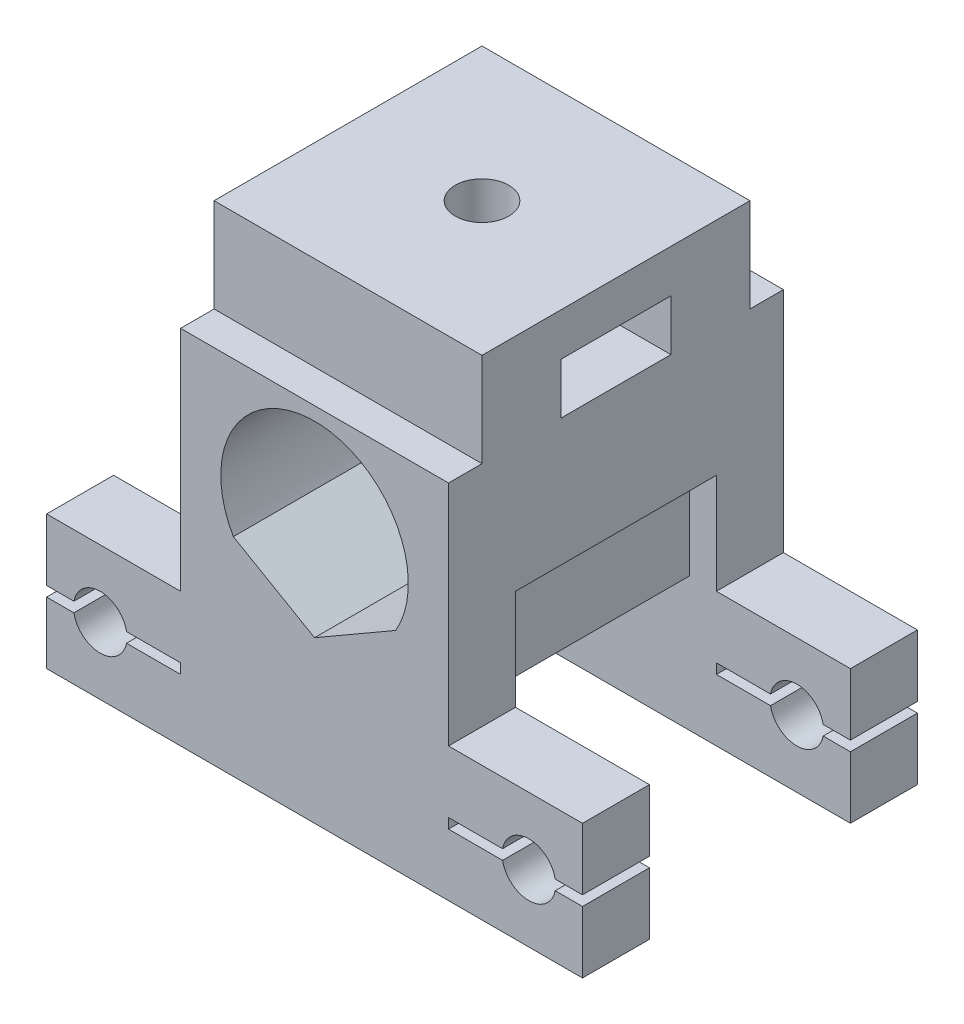
from build123d import *

# Parameters (mm, degrees)
SKETCH1_W               = 20
SKETCH1_H               = 25
BOSS_EXTRUDE1_DEPTH     = 17
CUT_EXTRUDE1_DEPTH      = 32.843366656
BOSS_EXTRUDE2_DEPTH     = 5
SKETCH4_R               = 2
CUT_EXTRUDE2_DEPTH      = 37.249137921
SKETCH6_W               = 20
SKETCH6_H               = 20
BOSS_EXTRUDE3_DEPTH     = 7
SKETCH8_W               = 8.2
SKETCH8_H               = 3.8
CUT_EXTRUDE3_DEPTH      = 41.401113846
CUT_EXTRUDE4_REACH      = 43.379
CUT_EXTRUDE4_END_RADIUS = 7
SKETCH7_R               = 2
SKETCH9_W               = 15
SKETCH9_H               = 7.5
CUT_EXTRUDE5_DEPTH      = 2
SKETCH10_W              = 10
SKETCH10_H              = 0.75
CUT_EXTRUDE6_DEPTH      = 41.01249811
CUT_EXTRUDE7_START      = 20
SKETCH9_2_W             = 15
SKETCH9_2_H             = 7.5
CUT_EXTRUDE7_DEPTH      = 2.5


with BuildPart() as part:
    # Sketch1 → Boss-Extrude1 (new body)
    with BuildSketch(Plane(origin=(0, 0, 0), x_dir=(1, 0, 0), z_dir=(0, 1, 0))):
        Rectangle(SKETCH1_W, SKETCH1_H)
    extrude(amount=BOSS_EXTRUDE1_DEPTH)

    # Sketch2 → Cut-Extrude1 (cut, through all)
    with BuildSketch(Plane.XY.offset(12.5)):
        with BuildLine():
            Line((0, 2), (-6.062177826, 5.5))
            ThreePointArc((-6.062177826, 5.5), (0, 16), (6.062177826, 5.5))
            Line((6.062177826, 5.5), (0, 2))
        make_face()
    extrude(amount=-CUT_EXTRUDE1_DEPTH, mode=Mode.SUBTRACT)

    # Sketch3 → Boss-Extrude2 (add)
    with BuildSketch(Plane.XY.offset(12.5)):
        Polygon((10, 0), (20, 0), (20, -10), (-20, -10), (-20, 0), (-10, 0), align=None)
    boss_extrude2 = extrude(amount=-BOSS_EXTRUDE2_DEPTH)

    # Mirror1: Boss-Extrude2 across plane
    add(boss_extrude2.mirror(Plane.XY))

    # Sketch4 → Cut-Extrude2 (cut, through all)
    with BuildSketch(Plane.XY.offset(12.5)):
        with Locations((16, -5)):
            Circle(SKETCH4_R)
        with Locations((-16, -5)):
            Circle(SKETCH4_R)
    extrude(amount=-CUT_EXTRUDE2_DEPTH, mode=Mode.SUBTRACT)

    # Sketch6 → Boss-Extrude3 (add)
    with BuildSketch(Plane(origin=(0, 17, 0), x_dir=(1, 0, 0), z_dir=(0, 1, 0))):
        Rectangle(SKETCH6_W, SKETCH6_H)
    extrude(amount=BOSS_EXTRUDE3_DEPTH)

    # Sketch8 → Cut-Extrude3 (cut, through all)
    with BuildSketch(Plane(origin=(10, 0, 0), x_dir=(0, 0, -1), z_dir=(1, 0, 0))):
        with Locations((0, 18.9)):
            Rectangle(SKETCH8_W, SKETCH8_H)
    extrude(amount=-CUT_EXTRUDE3_DEPTH, mode=Mode.SUBTRACT)

    # Cut-Extrude4: up to this cylinder (the profile starts outside it)
    cut_extrude4_end = Plane(origin=(0, 9, 0), z_dir=(0, 0, 1)) * Cylinder(CUT_EXTRUDE4_END_RADIUS, 101.758, mode=Mode.PRIVATE)
    # Sketch7 → Cut-Extrude4 (cut, up to the surface)
    with BuildSketch(Plane(origin=(0, 24, 0), x_dir=(1, 0, 0), z_dir=(0, 1, 0)), mode=Mode.PRIVATE) as cut_extrude4_sk1:
        with Locations(Location((0, 0, 0), (0, 0, 270))):
            Circle(SKETCH7_R)
    cut_extrude4_tool1 = extrude(cut_extrude4_sk1.sketch, amount=-CUT_EXTRUDE4_REACH, mode=Mode.PRIVATE) - cut_extrude4_end
    add(cut_extrude4_tool1.solids().sort_by_distance((0, 24, 0))[0], mode=Mode.SUBTRACT)

    # Sketch9 → Cut-Extrude5 (cut)
    with BuildSketch(Plane.ZY.offset(-10)):
        with Locations((0, 3.75)):
            Rectangle(SKETCH9_W, SKETCH9_H)
    extrude(amount=CUT_EXTRUDE5_DEPTH, mode=Mode.SUBTRACT)

    # Sketch10 → Cut-Extrude6 (cut, through all)
    with BuildSketch(Plane.XY.offset(12.5)):
        with Locations((-15, -5)):
            Rectangle(SKETCH10_W, SKETCH10_H)
        with Locations((15, -5)):
            Rectangle(SKETCH10_W, SKETCH10_H)
    extrude(amount=-CUT_EXTRUDE6_DEPTH, mode=Mode.SUBTRACT)

    # Sketch9_2 → Cut-Extrude7 (cut)
    with BuildSketch(Plane.ZY.offset(-10).offset(CUT_EXTRUDE7_START)):
        with Locations((0, 3.75)):
            Rectangle(SKETCH9_2_W, SKETCH9_2_H)
    extrude(amount=-CUT_EXTRUDE7_DEPTH, mode=Mode.SUBTRACT)


solid = part.part
